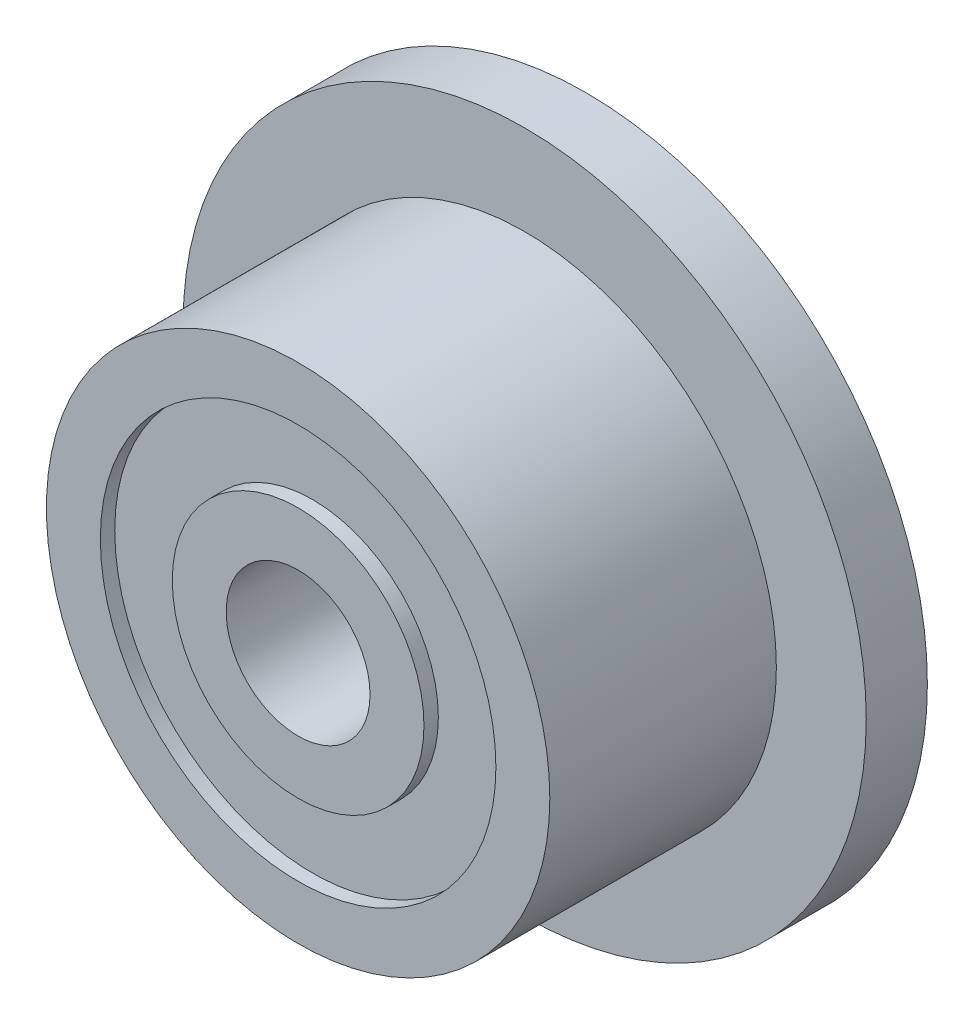
from build123d import *

# Parameters (mm, degrees)
SKETCH1_R           = 4.75
BOSS_EXTRUDE1_DEPTH = 0.85
SKETCH3_R           = 3.5
BOSS_EXTRUDE3_DEPTH = 3.15
SKETCH4_R           = 1
CUT_EXTRUDE1_DEPTH  = 4
SKETCH5_R           = 2.75
SKETCH5_R_2         = 1.75
CUT_EXTRUDE2_DEPTH  = 0.2
CUT_EXTRUDE3_START  = -0.2
SKETCH6_R           = 2.75
SKETCH6_R_2         = 1.75
CUT_EXTRUDE3_DEPTH  = 0.2


with BuildPart() as part:
    # Sketch1 → Boss-Extrude1 (new body)
    with BuildSketch(Plane.XY):
        Circle(SKETCH1_R)
    extrude(amount=BOSS_EXTRUDE1_DEPTH)

    # Sketch3 → Boss-Extrude3 (add)
    with BuildSketch(Plane.XY.offset(0.85)):
        Circle(SKETCH3_R)
    extrude(amount=BOSS_EXTRUDE3_DEPTH)

    # Sketch4 → Cut-Extrude1 (cut)
    with BuildSketch(Plane.XY.offset(4)):
        Circle(SKETCH4_R)
    extrude(amount=-CUT_EXTRUDE1_DEPTH, mode=Mode.SUBTRACT)

    # Sketch5 → Cut-Extrude2 (cut)
    with BuildSketch(Plane.XY.offset(4)):
        Circle(SKETCH5_R)
        Circle(SKETCH5_R_2, mode=Mode.SUBTRACT)
    extrude(amount=-CUT_EXTRUDE2_DEPTH, mode=Mode.SUBTRACT)

    # Sketch6 → Cut-Extrude3 (cut)
    with BuildSketch(Plane(origin=(0, 0, 0), x_dir=(-1, 0, 0), z_dir=(0, 0, -1)).offset(CUT_EXTRUDE3_START)):
        Circle(SKETCH6_R)
        Circle(SKETCH6_R_2, mode=Mode.SUBTRACT)
    extrude(amount=CUT_EXTRUDE3_DEPTH, mode=Mode.SUBTRACT)


solid = part.part
